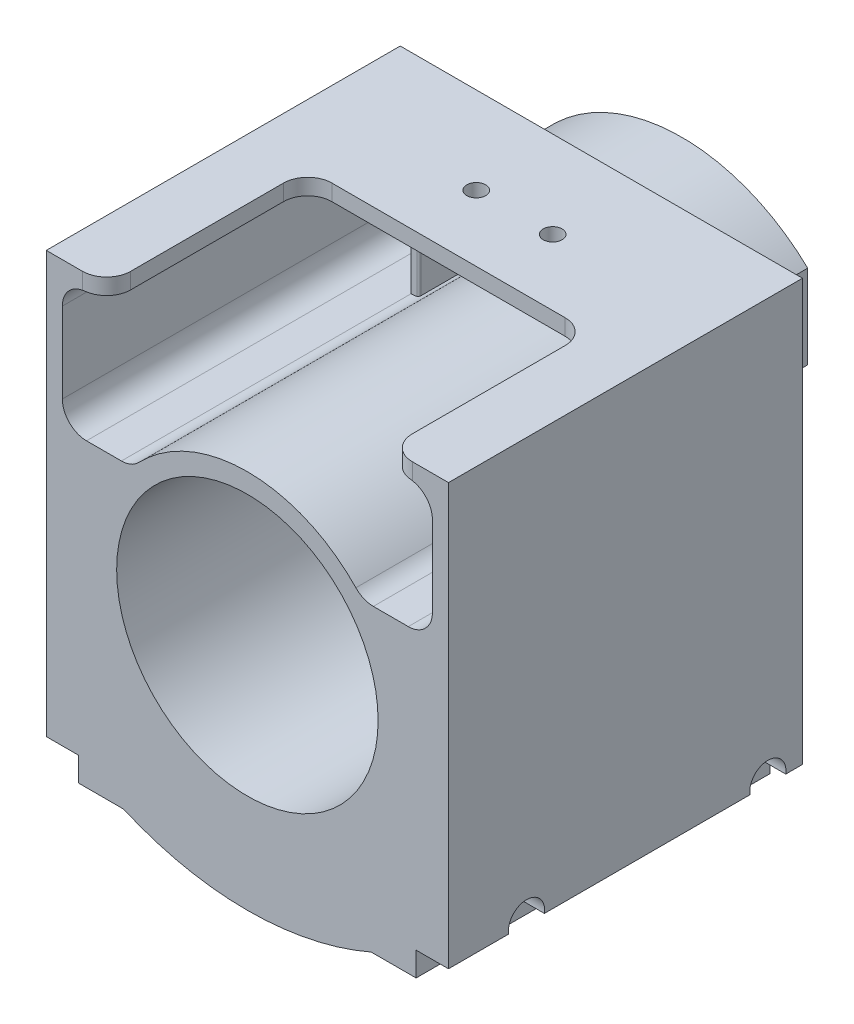
from build123d import *

# Parameters (mm, degrees)
BOSS_EXTRUDE2_START      = 6
BOSS_EXTRUDE2_DEPTH      = 44
SKETCH2_R                = 16.25
CUT_EXTRUDE1_DEPTH       = 1
CUT_EXTRUDE1_DEPTH_BACK  = 45
CUT_EXTRUDE3_DEPTH       = 45
FILLET1_R                = 3
SKETCH5_W                = 35
SKETCH5_H                = 25
CUT_EXTRUDE4_DEPTH       = 10
FILLET2_R                = 3
SKETCH6_R                = 16.25
SKETCH6_R_2              = 9.5
SKETCH6_R_3              = 1.65
BOSS_EXTRUDE3_DEPTH      = 5
SKETCH7_R                = 2.25
CUT_EXTRUDE5_DEPTH       = 26
CUT_EXTRUDE5_DEPTH_BACK  = 26
CUT_EXTRUDE6_REACH       = 60.55
SKETCH8_R                = 1.175
BOSS_EXTRUDE4_START      = -44
BOSS_EXTRUDE4_DEPTH      = 8
BOSS_EXTRUDE4_DEPTH_BACK = 10
FILLET5_R                = 0.25
FILLET6_R                = 0.25


with BuildPart() as part:
    # Sketch1 → Boss-Extrude2 (new body)
    with BuildSketch(Plane.XY.offset(BOSS_EXTRUDE2_START)):
        with BuildLine():
            Line((-25, 0), (-25, -29.344548046))
            Line((-25, -29.344548046), (-25, -32.344548046))
            Line((-25, -32.344548046), (-20.974572981, -32.344548046))
            Line((-20.974572981, -32.344548046), (-20.974572981, -35.344548046))
            Line((-20.974572981, -35.344548046), (-15.390432855, -35.344548046))
            ThreePointArc((-15.390432855, -35.344548046), (0, -38.55), (15.390432855, -35.344548046))
            Line((15.390432855, -35.344548046), (20.974572981, -35.344548046))
            Line((20.974572981, -35.344548046), (20.974572981, -32.344548046))
            Line((20.974572981, -32.344548046), (25, -32.344548046))
            Line((25, -32.344548046), (25, -29.344548046))
            Line((25, -29.344548046), (25, 0))
            Line((25, 0), (25, 20))
            Line((25, 20), (-25, 20))
            Line((-25, 20), (-25, 0))
        make_face()
    extrude(amount=BOSS_EXTRUDE2_DEPTH)

    # Sketch2 → Cut-Extrude1 (cut, two sides)
    with BuildSketch(Plane.XY.offset(50)) as cut_extrude1_sk:
        with Locations((0, -10)):
            Circle(SKETCH2_R)
    extrude(amount=CUT_EXTRUDE1_DEPTH, mode=Mode.SUBTRACT)
    extrude(cut_extrude1_sk.sketch, amount=-CUT_EXTRUDE1_DEPTH_BACK, mode=Mode.SUBTRACT)

    # Sketch4 → Cut-Extrude3 (cut, through all)
    with BuildSketch(Plane.XY.offset(50)):
        with BuildLine():
            Line((-23, 18), (23, 18))
            Line((23, 18), (23, 2))
            Line((23, 2), (14.317821063, 2))
            ThreePointArc((14.317821063, 2), (0, 8.681541692), (-14.317821063, 2))
            Line((-14.317821063, 2), (-23, 2))
            Line((-23, 2), (-23, 18))
        make_face()
    extrude(amount=-CUT_EXTRUDE3_DEPTH, mode=Mode.SUBTRACT)

    # Fillet1
    fillet1_edges = [part.edges().sort_by_distance(p)[0] for p in [
        (23, 18, 28),
        (23, 2, 28),
        (14.317821063, 2, 28),
        (-14.317821063, 2, 28),
        (-23, 2, 28),
        (-23, 18, 28),
    ]]
    fillet(fillet1_edges, radius=FILLET1_R)

    # Sketch5 → Cut-Extrude4 (cut)
    with BuildSketch(Plane(origin=(0, 20, 0), x_dir=(1, 0, 0), z_dir=(0, 1, 0))):
        with Locations((0, -37.5)):
            Rectangle(SKETCH5_W, SKETCH5_H)
    extrude(amount=-CUT_EXTRUDE4_DEPTH, mode=Mode.SUBTRACT)

    # Fillet2
    fillet2_edges = [part.edges().sort_by_distance(p)[0] for p in [
        (17.5, 19, 50),
        (17.5, 19, 25),
        (-17.5, 19, 25),
        (-17.5, 19, 50),
    ]]
    fillet(fillet2_edges, radius=FILLET2_R)

    # Sketch6 → Boss-Extrude3 (add)
    with BuildSketch(Plane.XY.offset(14)):
        with Locations((0, -10)):
            Circle(SKETCH6_R)
        with Locations((0, -10)):
            Circle(SKETCH6_R_2, mode=Mode.SUBTRACT)
        with Locations((4.446261863, 2.21600407)):
            Circle(SKETCH6_R_3, mode=Mode.SUBTRACT)
        with Locations((12.21600407, -14.446261863)):
            Circle(SKETCH6_R_3, mode=Mode.SUBTRACT)
        with Locations((-4.446261863, -22.21600407)):
            Circle(SKETCH6_R_3, mode=Mode.SUBTRACT)
        with Locations((-12.21600407, -5.553738137)):
            Circle(SKETCH6_R_3, mode=Mode.SUBTRACT)
    extrude(amount=-BOSS_EXTRUDE3_DEPTH)

    # Sketch7 → Cut-Extrude5 (cut, two sides)
    with BuildSketch(Plane(origin=(0, 0, 0), x_dir=(0, 0, -1), z_dir=(1, 0, 0))) as cut_extrude5_sk:
        with Locations((-40.3, -32)):
            Circle(SKETCH7_R)
        with Locations((-10.3, -32)):
            Circle(SKETCH7_R)
    extrude(amount=CUT_EXTRUDE5_DEPTH, mode=Mode.SUBTRACT)
    extrude(cut_extrude5_sk.sketch, amount=-CUT_EXTRUDE5_DEPTH_BACK, mode=Mode.SUBTRACT)

    # Sketch8 → Cut-Extrude6 (cut, up to next)
    with BuildSketch(Plane(origin=(0, 20, 0), x_dir=(1, 0, 0), z_dir=(0, 1, 0)), mode=Mode.PRIVATE) as cut_extrude6_sk1:
        with Locations((-4.75, -16.8)):
            Circle(SKETCH8_R)
    cut_extrude6_tool1 = extrude(cut_extrude6_sk1.sketch, amount=-CUT_EXTRUDE6_REACH, mode=Mode.PRIVATE) & part.part
    add(cut_extrude6_tool1.solids().sort_by_distance((-4.75, 20, 16.8))[0], mode=Mode.SUBTRACT)
    # Sketch8 → Cut-Extrude6 (cut, up to next)
    with BuildSketch(Plane(origin=(0, 20, 0), x_dir=(1, 0, 0), z_dir=(0, 1, 0)), mode=Mode.PRIVATE) as cut_extrude6_sk2:
        with Locations((4.75, -16.8)):
            Circle(SKETCH8_R)
    cut_extrude6_tool2 = extrude(cut_extrude6_sk2.sketch, amount=-CUT_EXTRUDE6_REACH, mode=Mode.PRIVATE) & part.part
    add(cut_extrude6_tool2.solids().sort_by_distance((4.75, 20, 16.8))[0], mode=Mode.SUBTRACT)

    # Sketch9 → Boss-Extrude4 (add, two sides)
    with BuildSketch(Plane.XY.offset(50).offset(BOSS_EXTRUDE4_START)) as boss_extrude4_sk:
        with BuildLine():
            ThreePointArc((-14.655326574, 2.171572875), (-15.148020638, 2.043204321), (-15.655326574, 2))
            Line((-15.655326574, 2), (-15.655326574, 1))
            ThreePointArc((-15.655326574, 1), (-14.085187018, 1.32105154), (-12.767095323, 2.232669113))
            ThreePointArc((-12.767095323, 2.232669113), (0, 7.681541692), (12.767095323, 2.232669113))
            ThreePointArc((12.767095323, 2.232669113), (14.085187018, 1.32105154), (15.655326574, 1))
            Line((15.655326574, 1), (15.655326574, 2))
            ThreePointArc((15.655326574, 2), (15.148020638, 2.043204321), (14.655326574, 2.171572875))
            ThreePointArc((14.655326574, 2.171572875), (14.028093012, 2.479660552), (13.489153136, 2.924501835))
            ThreePointArc((13.489153136, 2.924501835), (0, 8.681541692), (-13.489153136, 2.924501835))
            ThreePointArc((-13.489153136, 2.924501835), (-14.028093012, 2.479660552), (-14.655326574, 2.171572875))
        make_face()
        with BuildLine():
            Line((-15.655326574, 11.412284527), (-15.655326574, 2))
            ThreePointArc((-15.655326574, 2), (-15.148020638, 2.043204321), (-14.655326574, 2.171572875))
            Line((-14.655326574, 2.171572875), (-14.655326574, 10.53248927))
            ThreePointArc((-14.655326574, 10.53248927), (-14.566443026, 10.944638287), (-14.31559295, 11.283520769))
            ThreePointArc((-14.31559295, 11.283520769), (0, 16.681541692), (14.31559295, 11.283520769))
            ThreePointArc((14.31559295, 11.283520769), (14.566443026, 10.944638287), (14.655326574, 10.53248927))
            Line((14.655326574, 10.53248927), (14.655326574, 2.171572875))
            ThreePointArc((14.655326574, 2.171572875), (15.148020638, 2.043204321), (15.655326574, 2))
            Line((15.655326574, 2), (15.655326574, 11.412284527))
            ThreePointArc((15.655326574, 11.412284527), (0, 17.681541692), (-15.655326574, 11.412284527))
        make_face()
    extrude(amount=BOSS_EXTRUDE4_DEPTH)
    extrude(boss_extrude4_sk.sketch, amount=-BOSS_EXTRUDE4_DEPTH_BACK)

    # Fillet5
    fillet5_edges = [part.edges().sort_by_distance(p)[0] for p in [
        (0, 8.681541692, -4),
        (14.566443026, 10.944638287, -4),
        (0, 16.681541692, -4),
        (-14.566443026, 10.944638287, -4),
        (-14.028093012, 2.479660552, -4),
        (14.028093012, 2.479660552, -4),
        (14.655326574, 6.352031072, -4),
        (-14.655326574, 6.352031072, -4),
    ]]
    fillet(fillet5_edges, radius=FILLET5_R)

    # Fillet6
    fillet6_edges = [part.edges().sort_by_distance(p)[0] for p in [
        (-14.655326574, 6.352031072, 14),
        (0, 16.681541692, 14),
        (14.566443026, 10.944638287, 14),
        (14.655326574, 6.352031072, 14),
        (-14.566443026, 10.944638287, 14),
    ]]
    fillet(fillet6_edges, radius=FILLET6_R)


solid = part.part
